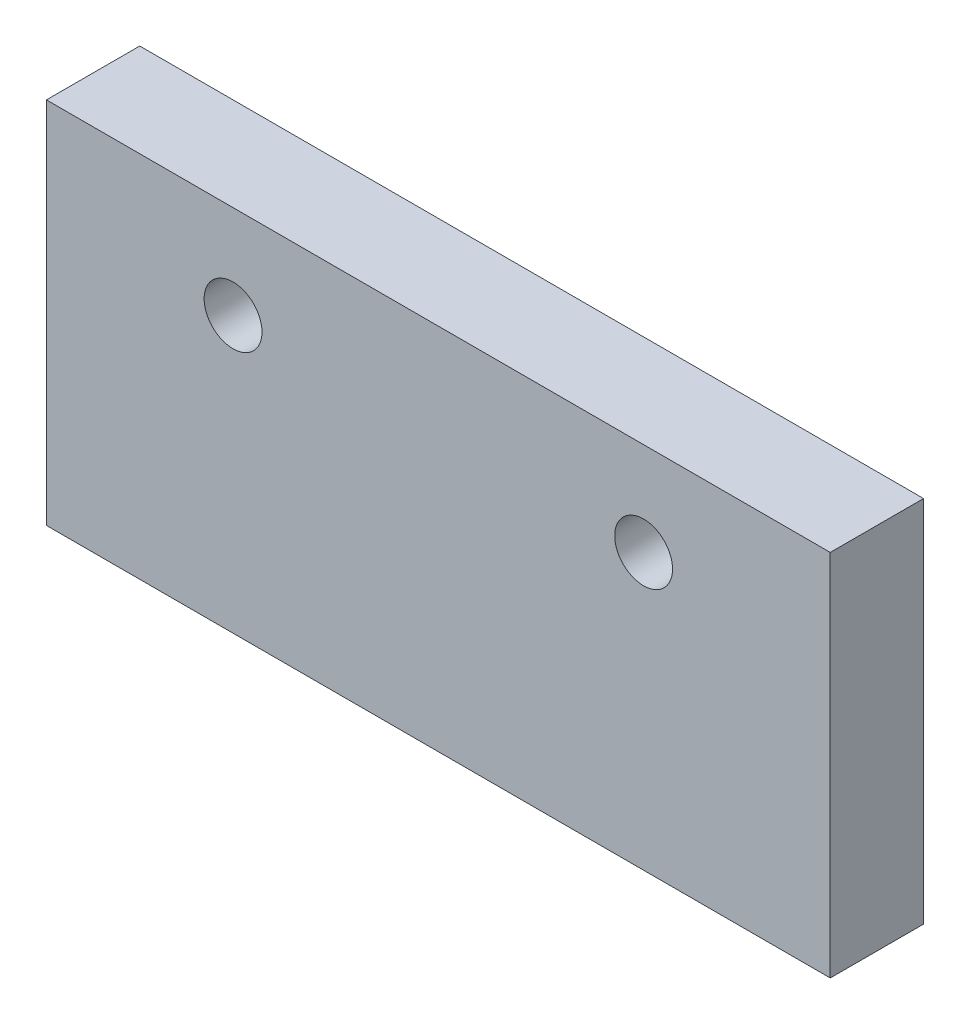
from build123d import *

# Parameters (mm, degrees)
SKETCH_1_R      = 1.55
EXTRUDE_1_DEPTH = 5


with BuildPart() as part:
    # 草图1 → 凸台-拉伸1 (new body)
    with BuildSketch(Plane.XY):
        Polygon((42, 17), (0, 17), (0, 7), (0, 0), (0, -2.75), (42, -2.75), (42, 0), (42, 7), align=None)
        with Locations((10, 12)):
            Circle(SKETCH_1_R, mode=Mode.SUBTRACT)
        with Locations((32, 12)):
            Circle(SKETCH_1_R, mode=Mode.SUBTRACT)
    extrude(amount=EXTRUDE_1_DEPTH)


solid = part.part
